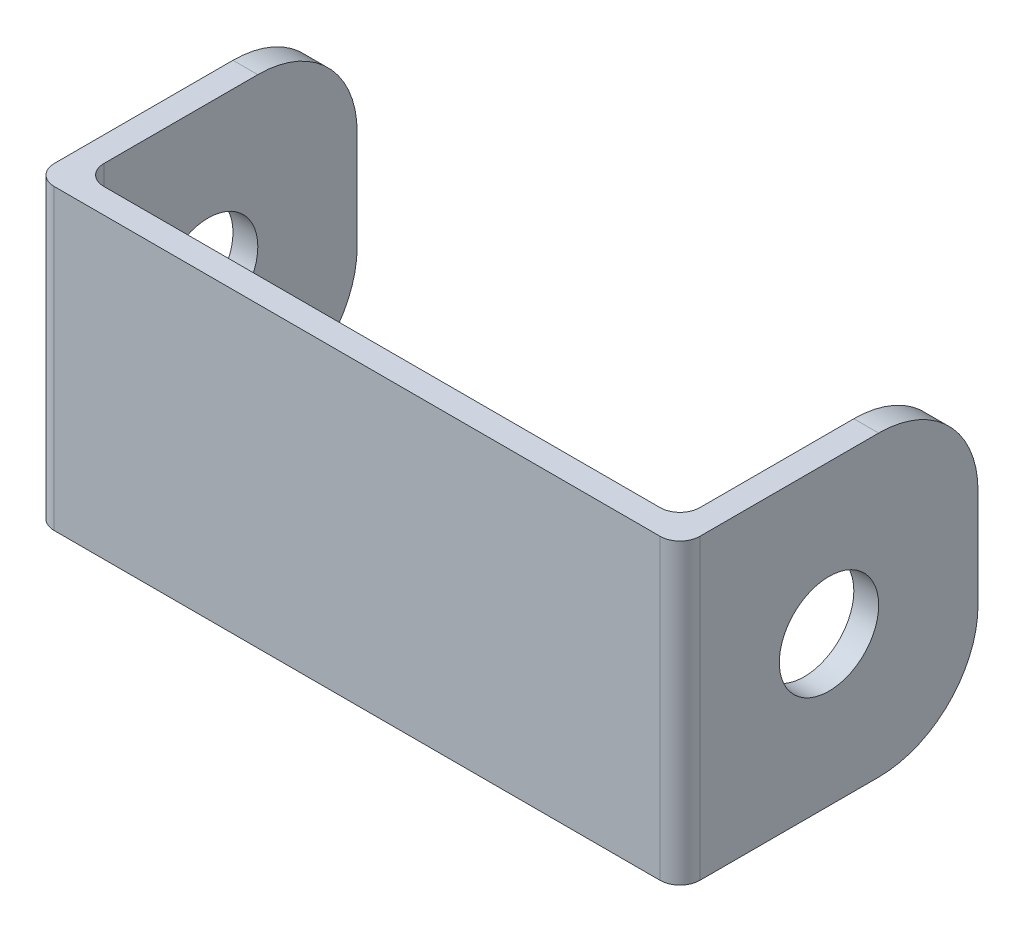
from build123d import *

# Parameters (mm, degrees)
BOSS_EXTRUDE1_DEPTH = 38.1
SKETCH4_R           = 6.35
CUT_EXTRUDE1_DEPTH  = 83.55
FILLET1_R           = 12.7
FILLET2_R           = 2.54


with BuildPart() as part:
    # Sketch1 → Boss-Extrude1 (new body)
    with BuildSketch(Plane(origin=(0, 0, 0), x_dir=(1, 0, 0), z_dir=(0, 1, 0))):
        Polygon((-11.90625, 27.9796875), (-11.90625, -10.1203125), (70.64375, -10.1203125), (70.64375, 27.9796875), (67.46875, 27.9796875), (67.46875, -6.9453125), (-8.73125, -6.9453125), (-8.73125, 27.9796875), align=None)
    extrude(amount=BOSS_EXTRUDE1_DEPTH)

    # Sketch4 → Cut-Extrude1 (cut, through all)
    with BuildSketch(Plane(origin=(70.64375, 0, 0), x_dir=(0, 0, -1), z_dir=(1, 0, 0))):
        with Locations((8.9296875, 19.05)):
            Circle(SKETCH4_R)
    extrude(amount=-CUT_EXTRUDE1_DEPTH, mode=Mode.SUBTRACT)

    # Fillet1
    fillet1_edges = [part.edges().sort_by_distance(p)[0] for p in [
        (-10.31875, 0, -27.9796875),
        (69.05625, 38.1, -27.9796875),
        (-10.31875, 38.1, -27.9796875),
        (69.05625, 0, -27.9796875),
    ]]
    fillet(fillet1_edges, radius=FILLET1_R)

    # Fillet2
    fillet2_edges = [part.edges().sort_by_distance(p)[0] for p in [
        (-8.73125, 19.05, 6.9453125),
        (67.46875, 19.05, 6.9453125),
        (70.64375, 19.05, 10.1203125),
        (-11.90625, 19.05, 10.1203125),
    ]]
    fillet(fillet2_edges, radius=FILLET2_R)


solid = part.part
